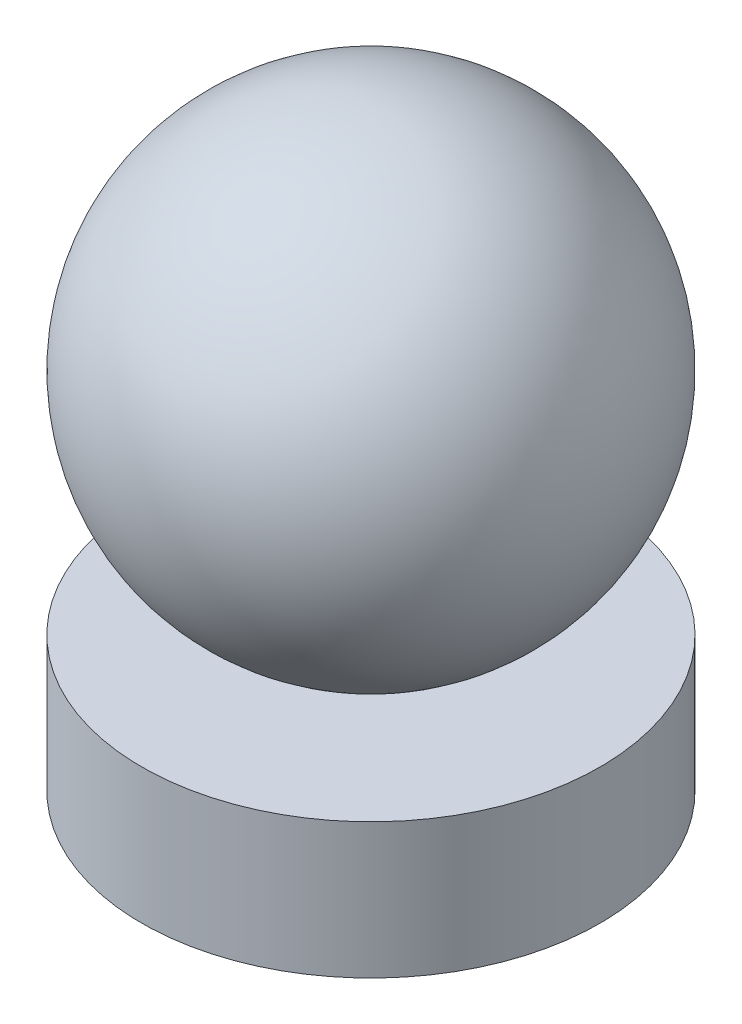
from build123d import *

# Parameters (mm, degrees)
SKETCH1_W = 3.175
SKETCH1_H = 1.875


with BuildPart() as part:
    # Sketch1 → Revolve1 (revolve)
    with BuildSketch(Plane.XY):
        with BuildLine():
            ThreePointArc((0, 8.225), (3.175, 5.05), (0, 1.875))
            Line((0, 1.875), (0, 8.225))
        make_face()
        with Locations((1.5875, 0.9375)):
            Rectangle(SKETCH1_W, SKETCH1_H)
    revolve(axis=Axis((0, 0, 0), (0, 1, 0)))


solid = part.part
